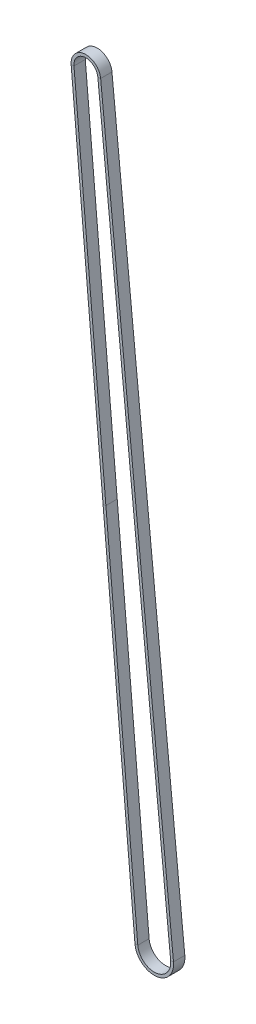
from build123d import *

# Parameters (mm, degrees)
SKETCH2_W = 1.5
SKETCH2_H = 6


with BuildPart() as part:
    # Sweep1: sweep along a path in Sketch1
    with BuildLine(Plane.XY) as sweep1_path:
        Line((-42.529793069, 385.761298089), (-8.716710208, -0.762537307))
        ThreePointArc((-8.716710208, -0.762537307), (0.816439483, -8.711826822), (8.706610119, 0.870310423))
        Line((8.706610119, 0.870310423), (-29.885440603, 386.946279013))
        ThreePointArc((-29.885440603, 386.946279013), (-36.796453743, 392.636979485), (-42.529793069, 385.761298089))
    # Sketch2 → Sweep1 (sweep)
    with BuildSketch(Plane(origin=(-25.623251639, 192.499380391, 0), x_dir=(-0.996195452, -0.087147121, 0), z_dir=(0.087147121, -0.996195452, 0))):
        with Locations((0.75, 0)):
            Rectangle(SKETCH2_W, SKETCH2_H)
    sweep(path=sweep1_path.line)


solid = part.part
